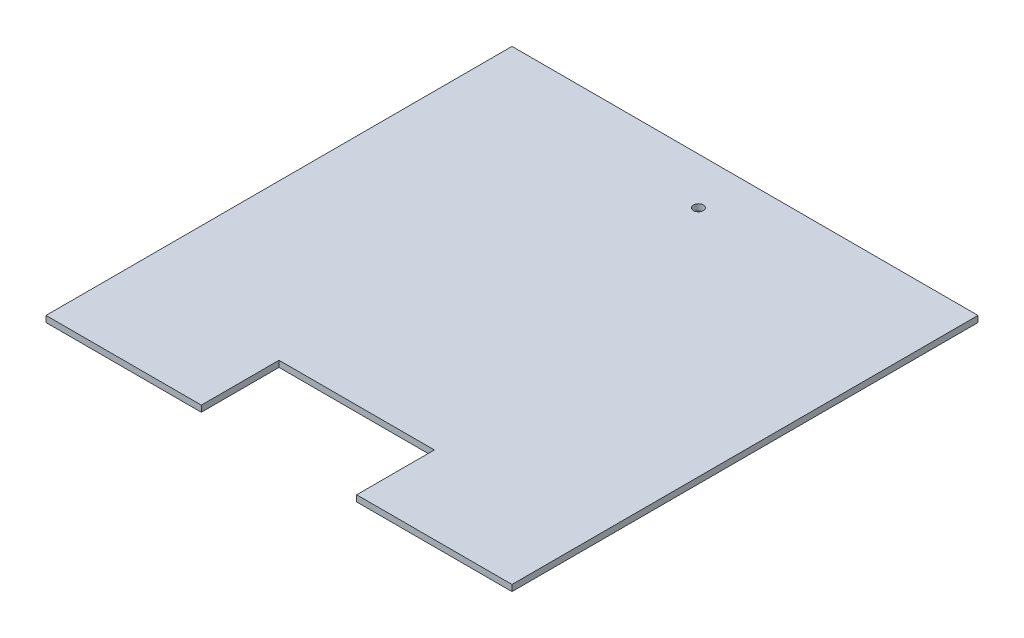
from build123d import *

# Parameters (mm, degrees)
SKETCH1_W           = 190.5
SKETCH1_H           = 190.5
BOSS_EXTRUDE1_DEPTH = 2.54
SKETCH2_W           = 63.5
SKETCH2_H           = 31.75
CUT_EXTRUDE1_DEPTH  = 2.54
SKETCH3_R           = 2.032
CUT_EXTRUDE2_DEPTH  = 2.54


with BuildPart() as part:
    # Sketch1 → Boss-Extrude1 (new body)
    with BuildSketch(Plane(origin=(0, 0, 0), x_dir=(1, 0, 0), z_dir=(0, 1, 0))):
        Rectangle(SKETCH1_W, SKETCH1_H)
    extrude(amount=BOSS_EXTRUDE1_DEPTH)

    # Sketch2 → Cut-Extrude1 (cut)
    with BuildSketch(Plane(origin=(0, 2.54, 0), x_dir=(1, 0, 0), z_dir=(0, 1, 0))):
        with Locations((0, -79.375)):
            Rectangle(SKETCH2_W, SKETCH2_H)
    extrude(amount=-CUT_EXTRUDE1_DEPTH, mode=Mode.SUBTRACT)

    # Sketch3 → Cut-Extrude2 (cut)
    with BuildSketch(Plane(origin=(0, 2.54, 0), x_dir=(1, 0, 0), z_dir=(0, 1, 0))):
        with Locations((0.000813673, 76.199186327)):
            Circle(SKETCH3_R)
    extrude(amount=-CUT_EXTRUDE2_DEPTH, mode=Mode.SUBTRACT)


solid = part.part
